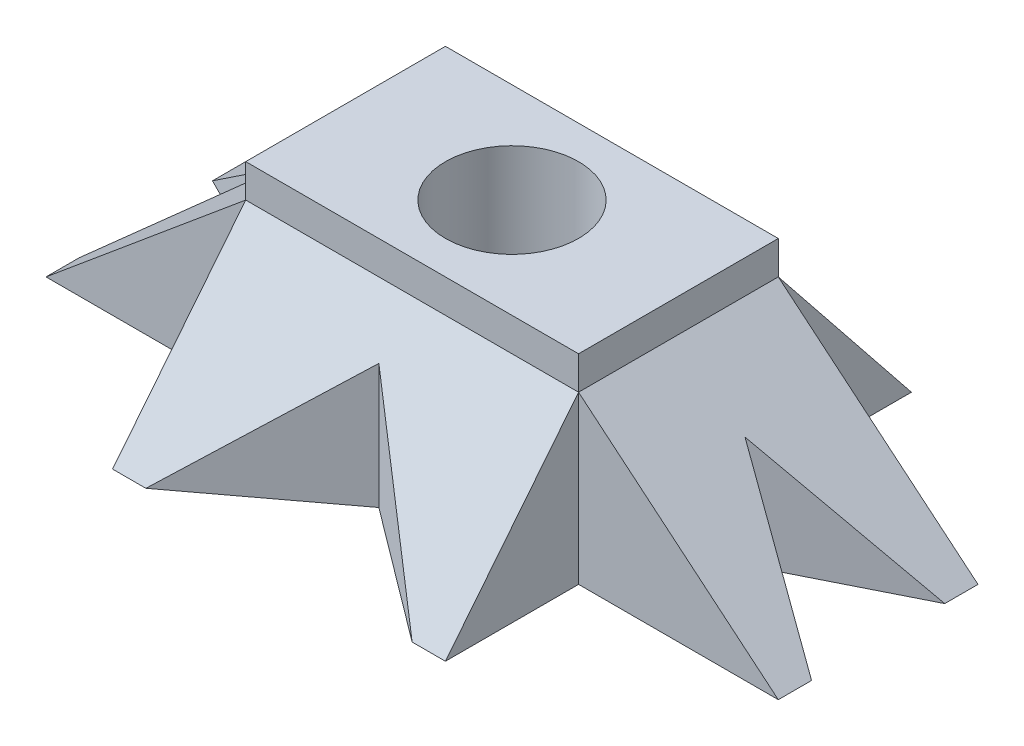
from build123d import *

# Parameters (mm, degrees)
SKETCH1_W           = 100
SKETCH1_H           = 60
SKETCH1_R           = 20
BOSS_EXTRUDE1_DEPTH = 60
BOSS_EXTRUDE2_DEPTH = 30
BOSS_EXTRUDE3_DEPTH = 50
CUT_EXTRUDE1_DEPTH  = 61


with BuildPart() as part:
    # Sketch1 → Boss-Extrude1 (new body)
    with BuildSketch(Plane(origin=(0, 0, 0), x_dir=(1, 0, 0), z_dir=(0, 1, 0))):
        Rectangle(SKETCH1_W, SKETCH1_H)
        Circle(SKETCH1_R, mode=Mode.SUBTRACT)
    extrude(amount=BOSS_EXTRUDE1_DEPTH)

    # Sketch3 → Boss-Extrude2 (add, symmetric)
    with BuildSketch(Plane.XY):
        Polygon((50, 0), (50, 50), (110, 0), align=None)
        Polygon((-110, 0), (-50, 0), (-50, 50), align=None)
    extrude(amount=BOSS_EXTRUDE2_DEPTH, both=True)

    # Sketch4 → Boss-Extrude3 (add, symmetric)
    with BuildSketch(Plane(origin=(0, 0, 0), x_dir=(0, 0, -1), z_dir=(1, 0, 0))):
        Polygon((-30, 0), (-30, 50), (-70, 0), align=None)
        Polygon((30, 0), (30, 50), (70, 0), align=None)
    extrude(amount=BOSS_EXTRUDE3_DEPTH, both=True)

    # Sketch5 → Cut-Extrude1 (cut, through all)
    with BuildSketch(Plane(origin=(0, 0, 0), x_dir=(1, 0, 0), z_dir=(0, 1, 0))):
        Polygon((-40, -70), (0, -40), (40, -70), align=None)
        Polygon((0, 40), (40, 70), (-40, 70), align=None)
        Polygon((110, -20), (70, 0), (110, 20), align=None)
        Polygon((-110, 20), (-110, -20), (-70, 0), align=None)
    extrude(amount=CUT_EXTRUDE1_DEPTH, mode=Mode.SUBTRACT)


solid = part.part
